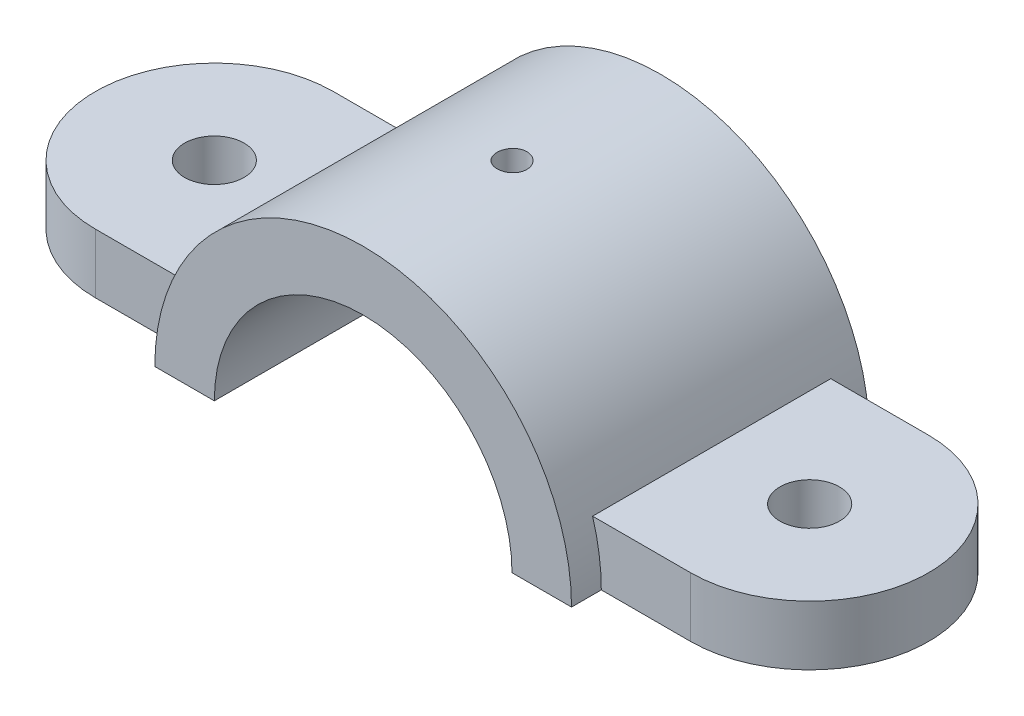
from build123d import *

# Parameters (mm, degrees)
SKETCH1_R           = 6.35
BOSS_EXTRUDE1_DEPTH = 12.7
BOSS_EXTRUDE2_DEPTH = 31.75
SKETCH3_R           = 31.75
CUT_EXTRUDE1_DEPTH  = 31.75
SKETCH4_R           = 3.175
CUT_EXTRUDE2_DEPTH  = 63.5


with BuildPart() as part:
    # Sketch1 → Boss-Extrude1 (new body)
    with BuildSketch(Plane(origin=(0, 0, 0), x_dir=(1, 0, 0), z_dir=(0, 1, 0))):
        with BuildLine():
            Line((-63.5, 25.4), (63.5, 25.4))
            ThreePointArc((63.5, 25.4), (88.9, 0), (63.5, -25.4))
            Line((63.5, -25.4), (-63.5, -25.4))
            ThreePointArc((-63.5, -25.4), (-88.9, 0), (-63.5, 25.4))
        make_face()
        with Locations(Location((-63.5, 0, 0), (0, 0, 270))):  # turned: the seam where the file's is
            Circle(SKETCH1_R, mode=Mode.SUBTRACT)
        with Locations(Location((63.5, 0, 0), (0, 0, 270))):  # turned: the seam where the file's is
            Circle(SKETCH1_R, mode=Mode.SUBTRACT)
    extrude(amount=BOSS_EXTRUDE1_DEPTH)

    # Sketch2 → Boss-Extrude2 (add, symmetric)
    with BuildSketch(Plane.XY):
        with BuildLine():
            Line((-44.45, 0), (44.45, 0))
            ThreePointArc((44.45, 0), (0, 44.45), (-44.45, 0))
        make_face()
    extrude(amount=BOSS_EXTRUDE2_DEPTH, both=True)

    # Sketch3 → Cut-Extrude1 (cut, symmetric)
    with BuildSketch(Plane.XY):
        Circle(SKETCH3_R)
    extrude(amount=CUT_EXTRUDE1_DEPTH, both=True, mode=Mode.SUBTRACT)

    # Sketch4 → Cut-Extrude2 (cut)
    with BuildSketch(Plane(origin=(0, 0, 0), x_dir=(1, 0, 0), z_dir=(0, 1, 0))):
        with Locations(Location((0, 0, 0), (0, 0, 90))):  # turned: the seam where the file's is
            Circle(SKETCH4_R)
    extrude(amount=CUT_EXTRUDE2_DEPTH, mode=Mode.SUBTRACT)


solid = part.part
